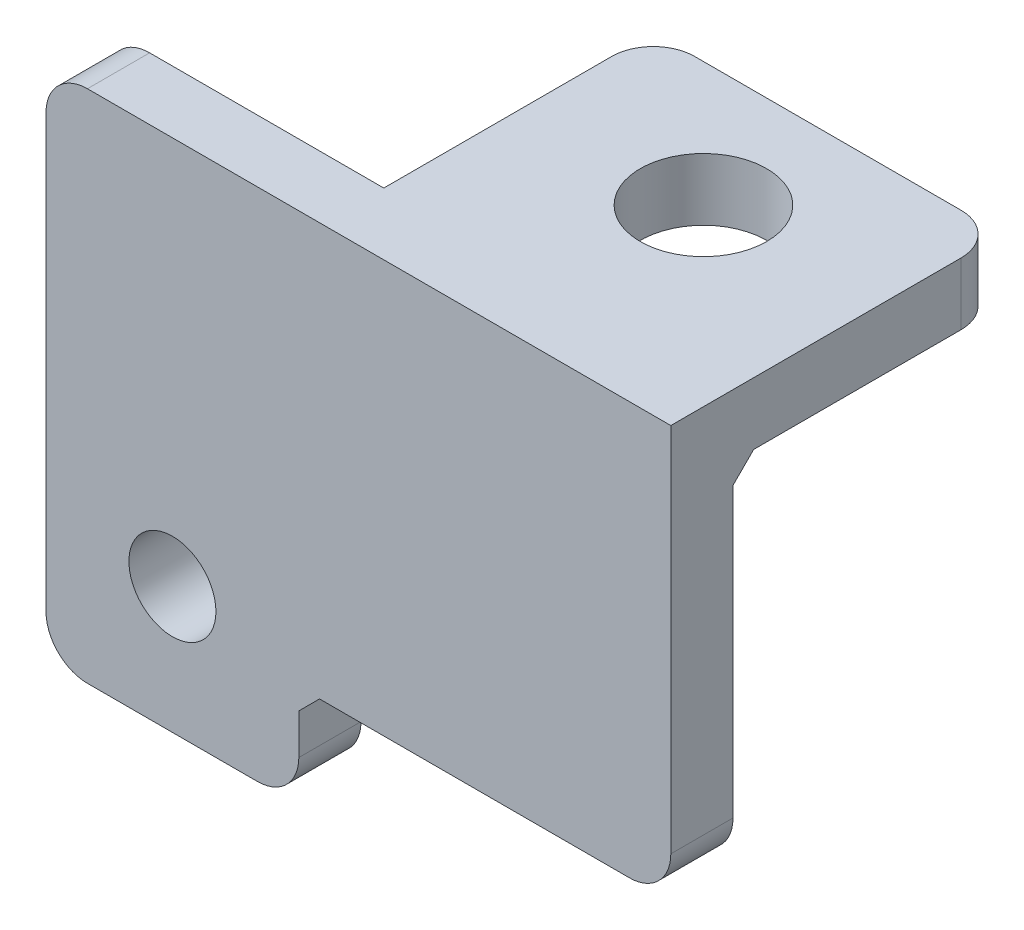
from build123d import *

# Parameters (mm, degrees)
SKETCH1_R           = 2.1
BOSS_EXTRUDE1_DEPTH = 3
SKETCH2_W           = 16
SKETCH2_H           = 16.85
BOSS_EXTRUDE2_DEPTH = 3
SKETCH4_W           = 5.55
SKETCH4_H           = 1
BOSS_EXTRUDE3_DEPTH = 3
CHAMFER1_SIZE       = 1
SKETCH3_R           = 3.05
CUT_EXTRUDE1_DEPTH  = 4
FILLET1_R           = 2


with BuildPart() as part:
    # Sketch1 → Boss-Extrude1 (new body)
    with BuildSketch(Plane.XY):
        Polygon((-5.2, 77.75), (7, 77.75), (24.95, 77.75), (24.95, 57.85), (7, 57.85), (7, 52.9), (-5.2, 52.9), align=None)
        with Locations((0.9, 59)):
            Circle(SKETCH1_R, mode=Mode.SUBTRACT)
    extrude(amount=BOSS_EXTRUDE1_DEPTH)

    # Sketch2 → Boss-Extrude2 (add)
    with BuildSketch(Plane(origin=(-52.8, 77.75, 0), x_dir=(0, 0, -1), z_dir=(0, -1, 0))):
        with Locations((5, 69.325)):
            Rectangle(SKETCH2_W, SKETCH2_H)
    extrude(amount=BOSS_EXTRUDE2_DEPTH)

    # Sketch4 → Boss-Extrude3 (add)
    with BuildSketch(Plane(origin=(0, 0, 0), x_dir=(-1, 0, 0), z_dir=(0, 0, -1))):
        with Locations((-19.175, 58.35)):
            Rectangle(SKETCH4_W, SKETCH4_H)
    extrude(amount=BOSS_EXTRUDE3_DEPTH)

    # Chamfer1
    chamfer1_edges = [part.edges().sort_by_distance(p)[0] for p in [
        (7, 57.85, 1.5),
        (16.525, 74.75, 0),
        (19.175, 58.85, 0),
    ]]
    chamfer(chamfer1_edges, length=CHAMFER1_SIZE)

    # Sketch3 → Cut-Extrude1 (cut, through all)
    with BuildSketch(Plane(origin=(0, 74.75, 0), x_dir=(0, 0, -1), z_dir=(0, -1, 0))):
        with Locations((7, 16.525)):
            Circle(SKETCH3_R)
    extrude(amount=-CUT_EXTRUDE1_DEPTH, mode=Mode.SUBTRACT)

    # Fillet1
    fillet1_edges = [part.edges().sort_by_distance(p)[0] for p in [
        (-5.2, 77.75, 1.5),
        (24.95, 57.85, 1.5),
        (7, 52.9, 1.5),
        (-5.2, 52.9, 1.5),
        (24.95, 76.25, -13),
        (8.1, 76.25, -13),
    ]]
    fillet(fillet1_edges, radius=FILLET1_R)


solid = part.part
